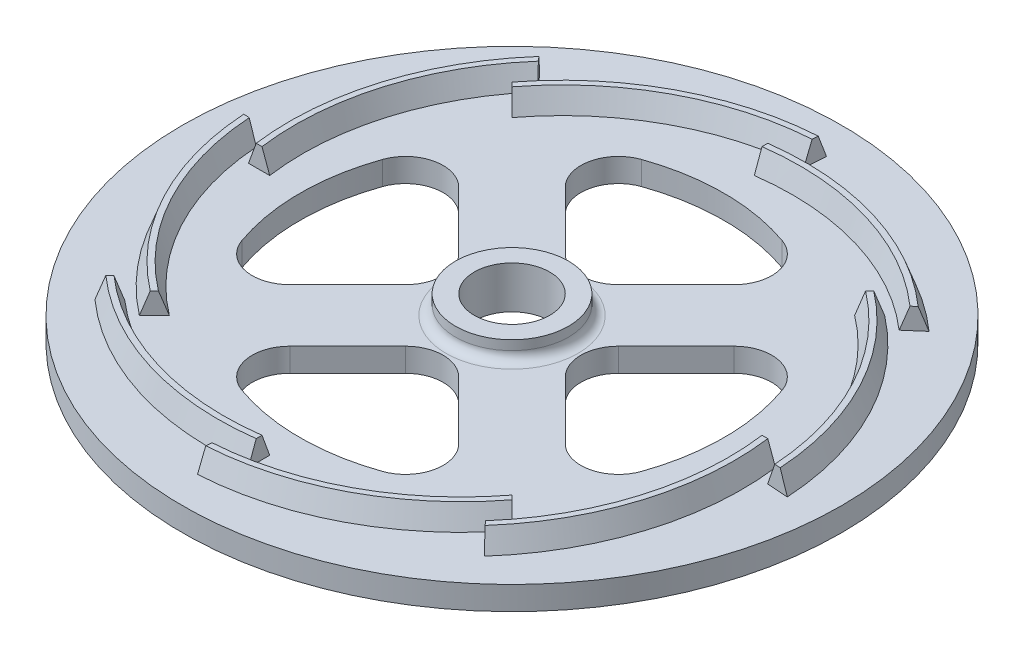
from build123d import *

# Parameters (mm, degrees)
SKETCH2_W           = 35
SKETCH2_H           = 2.5
SKETCH3_R           = 4
CUT_EXTRUDE1_DEPTH  = 3.5
CIRPATTERN1_COUNT   = 8
SKETCH11_R          = 6
SKETCH11_R_2        = 4
BOSS_EXTRUDE1_DEPTH = 2
FILLET1_R           = 1


with BuildPart() as part:
    # Sketch2 → Revolve1 (revolve)
    with BuildSketch(Plane.XY):
        with Locations((20.486722825, 7.5)):
            Rectangle(SKETCH2_W, SKETCH2_H)
    revolve(axis=Axis((2.986722825, 8.75, 0), (0, -1, 0)))

    # Sketch3 → Cut-Extrude1 (cut, through all)
    with BuildSketch(Plane(origin=(0, 8.75, 0), x_dir=(1, 0, 0), z_dir=(0, 1, 0))):
        with Locations((2.986722825, 0)):
            Circle(SKETCH3_R)
        with BuildLine():
            Line((11.953421812, 14.623553237), (5.81514995, 8.485281374))
            ThreePointArc((5.81514995, 8.485281374), (2.986722825, 7.313708499), (0.1582957, 8.485281374))
            Line((0.1582957, 8.485281374), (-5.979976162, 14.623553237))
            ThreePointArc((-5.979976162, 14.623553237), (-7.051976031, 18.338924141), (-4.478742954, 21.225381521))
            ThreePointArc((-4.478742954, 21.225381521), (2.986722825, 22.5), (10.452188604, 21.225381521))
            ThreePointArc((10.452188604, 21.225381521), (13.025421681, 18.338924141), (11.953421812, 14.623553237))
        make_face()
        with BuildLine():
            Line((11.953421812, -14.623553237), (5.81514995, -8.485281374))
            ThreePointArc((5.81514995, -8.485281374), (2.986722825, -7.313708499), (0.1582957, -8.485281374))
            Line((0.1582957, -8.485281374), (-5.979976162, -14.623553237))
            ThreePointArc((-5.979976162, -14.623553237), (-7.051976031, -18.338924141), (-4.478742954, -21.225381521))
            ThreePointArc((-4.478742954, -21.225381521), (2.986722825, -22.5), (10.452188604, -21.225381521))
            ThreePointArc((10.452188604, -21.225381521), (13.025421681, -18.338924141), (11.953421812, -14.623553237))
        make_face()
        with BuildLine():
            Line((-11.636830412, 8.966698987), (-5.498558549, 2.828427125))
            ThreePointArc((-5.498558549, 2.828427125), (-4.326985674, 0), (-5.498558549, -2.828427125))
            Line((-5.498558549, -2.828427125), (-11.636830412, -8.966698987))
            ThreePointArc((-11.636830412, -8.966698987), (-15.352201316, -10.038698856), (-18.238658696, -7.465465779))
            ThreePointArc((-18.238658696, -7.465465779), (-19.513277175, 0), (-18.238658696, 7.465465779))
            ThreePointArc((-18.238658696, 7.465465779), (-15.352201316, 10.038698856), (-11.636830412, 8.966698987))
        make_face()
        with BuildLine():
            Line((17.610276062, 8.966698987), (11.472004199, 2.828427125))
            ThreePointArc((11.472004199, 2.828427125), (10.300431324, 0), (11.472004199, -2.828427125))
            Line((11.472004199, -2.828427125), (17.610276062, -8.966698987))
            ThreePointArc((17.610276062, -8.966698987), (21.325646966, -10.038698856), (24.212104346, -7.465465779))
            ThreePointArc((24.212104346, -7.465465779), (25.486722825, 0), (24.212104346, 7.465465779))
            ThreePointArc((24.212104346, 7.465465779), (21.325646966, 10.038698856), (17.610276062, 8.966698987))
        make_face()
    extrude(amount=-CUT_EXTRUDE1_DEPTH, mode=Mode.SUBTRACT)

    # Sweep2: sweep along a path in Sketch9
    with BuildLine(Plane(origin=(0, 8.75, 0), x_dir=(1, 0, 0), z_dir=(0, 1, 0))) as sweep2_path:
        ThreePointArc((21.978484794, 18.991761969), (29.371276645, 10.5906167), (32.986722825, 0))
        ThreePointArc((32.986722825, 0), (33.102162214, -0.998284421), (33.182560833, -2))
    # Sketch1 → Sweep2 (sweep)
    with BuildSketch(Plane.XY):
        Polygon((34.11308378, 8.75), (33.294150753, 11), (32.679294897, 11), (31.86036187, 8.75), align=None)
    sweep2 = sweep(path=sweep2_path.line)

    # CirPattern1: Sweep2 ×8 about axis
    cirpattern1_axis = Axis((2.986722825, 6.25, 0), (0, 1, 0))
    for i in range(1, CIRPATTERN1_COUNT):
        add(sweep2.rotate(cirpattern1_axis, i * 360 / CIRPATTERN1_COUNT))

    # Sketch11 → Boss-Extrude1 (add)
    with BuildSketch(Plane(origin=(0, 8.75, 0), x_dir=(1, 0, 0), z_dir=(0, 1, 0))):
        with Locations((2.986722825, 0)):
            Circle(SKETCH11_R)
        with Locations((2.986722825, 0)):
            Circle(SKETCH11_R_2, mode=Mode.SUBTRACT)
    extrude(amount=BOSS_EXTRUDE1_DEPTH)

    # Fillet1
    fillet1_edges = [part.edges().sort_by_distance(p)[0] for p in [
        (-3.013277175, 8.75, 0),
    ]]
    fillet(fillet1_edges, radius=FILLET1_R)


solid = part.part
